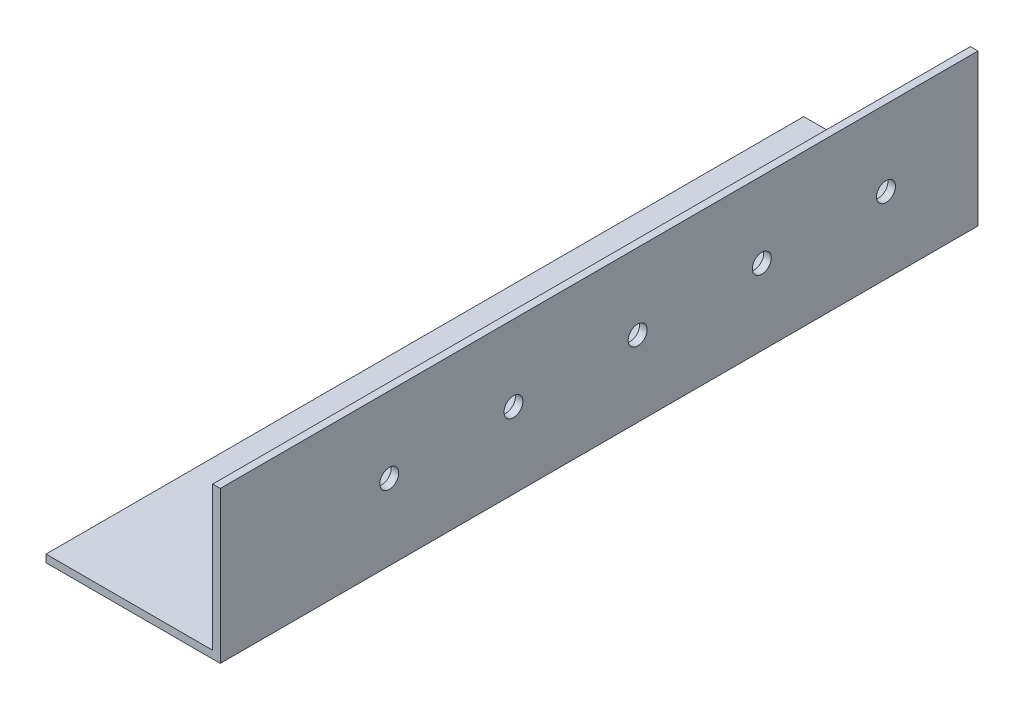
from build123d import *

# Parameters (mm, degrees)
SALIENTE_EXTRUIR1_DEPTH = 100
CROQUIS2_R              = 2.5
CORTAR_EXTRUIR1_DEPTH   = 10
CROQUIS3_W              = 8
CROQUIS3_H              = 40
CORTAR_EXTRUIR2_DEPTH   = 201


with BuildPart() as part:
    # Croquis1 → Saliente-Extruir1 (new body, symmetric)
    with BuildSketch(Plane.XY):
        Polygon((-27, 20), (-27, -20), (27, -20), (27, 20), (25, 20), (25, -18), (-25, -18), (-25, 20), align=None)
    extrude(amount=SALIENTE_EXTRUIR1_DEPTH, both=True)

    # Croquis2 → Cortar-Extruir1 (cut)
    with BuildSketch(Plane(origin=(27, 0, 0), x_dir=(0, 0, -1), z_dir=(1, 0, 0))):
        with Locations((-55.4, 0)):
            Circle(CROQUIS2_R)
        with Locations((-22.62, 0)):
            Circle(CROQUIS2_R)
        with Locations((10.16, 0)):
            Circle(CROQUIS2_R)
        with Locations((42.94, 0)):
            Circle(CROQUIS2_R)
        with Locations((75.72, 0)):
            Circle(CROQUIS2_R)
    extrude(amount=-CORTAR_EXTRUIR1_DEPTH, mode=Mode.SUBTRACT)

    # Croquis3 → Cortar-Extruir2 (cut, through all)
    with BuildSketch(Plane.XY.offset(100)):
        with Locations((-23, 0)):
            Rectangle(CROQUIS3_W, CROQUIS3_H)
    extrude(amount=-CORTAR_EXTRUIR2_DEPTH, mode=Mode.SUBTRACT)


solid = part.part
